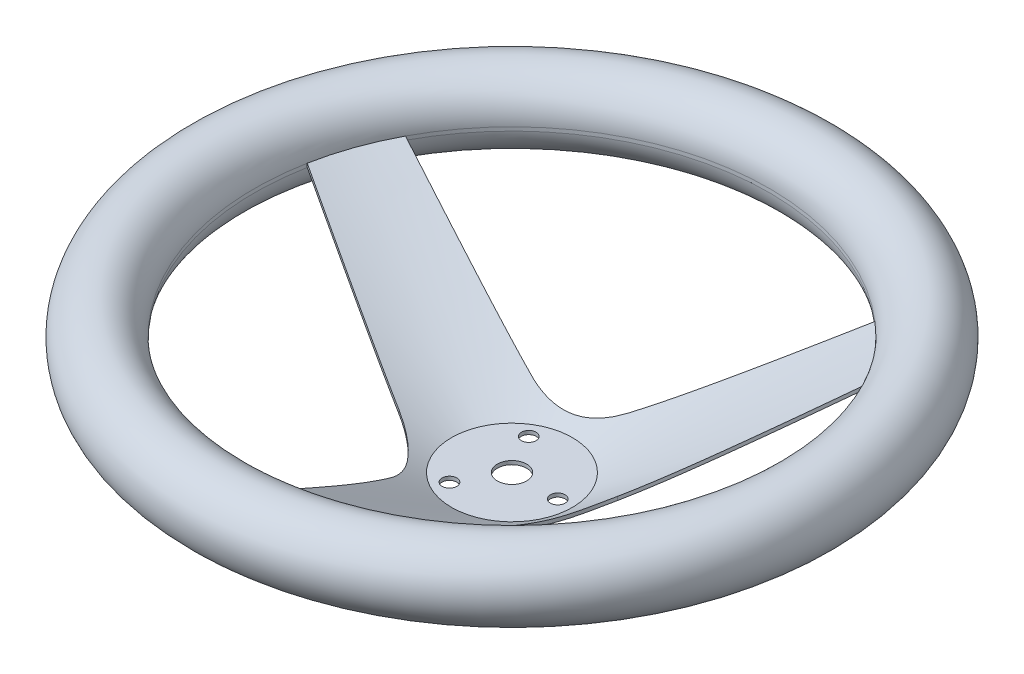
from build123d import *

# Parameters (mm, degrees)
SKETCH7_R           = 26.162
BOSS_EXTRUDE4_DEPTH = 52.3875
SKETCH8_R           = 26.162
CUT_EXTRUDE1_DEPTH  = 50.8
SKETCH9_R           = 15.621
CUT_EXTRUDE2_DEPTH  = 50.8
SKETCH11_R          = 6.35
SKETCH11_R_2        = 3.175
CUT_EXTRUDE3_DEPTH  = 2.54


with BuildPart() as part:
    # Sketch7 → Boss-Extrude4 (new body)
    with BuildSketch(Plane(origin=(0, 0, 0), x_dir=(1, 0, 0), z_dir=(0, 1, 0))):
        Circle(SKETCH7_R)
    extrude(amount=-BOSS_EXTRUDE4_DEPTH)

    # Sketch8 → Cut-Extrude1 (cut)
    with BuildSketch(Plane(origin=(0, 0, 0), x_dir=(1, 0, 0), z_dir=(0, 1, 0))):
        Circle(SKETCH8_R)
    extrude(amount=-CUT_EXTRUDE1_DEPTH, mode=Mode.SUBTRACT)

    # Sketch9 → Revolve4 (revolve)
    with BuildSketch(Plane.XY):
        with Locations((127, 0)):
            Circle(SKETCH9_R)
        with BuildLine():
            Line((111.379, 0), (26.162, -50.8))
            Line((26.162, -50.8), (26.162, -52.3875))
            Line((26.162, -52.3875), (111.455296032, -1.542018014))
            ThreePointArc((111.455296032, -1.542018014), (111.398085667, -0.771952174), (111.379, 0))
        make_face()
    revolve(axis=Axis((0, 0, 0), (0, -1, 0)))

    # Sketch10 → Cut-Extrude2 (cut)
    with BuildSketch(Plane(origin=(0, 0, 0), x_dir=(1, 0, 0), z_dir=(0, 1, 0))):
        with BuildLine():
            Line((94.435825911, 59.05215005), (40.549922786, 5.174980076))
            ThreePointArc((40.549922786, 5.174980076), (30.157026479, -10.65685708), (27.946773619, -29.465741782))
            Line((27.946773619, -29.465741782), (36.689563988, -105.162529141))
            ThreePointArc((36.689563988, -105.162529141), (105.071795381, -36.94860561), (94.435825911, 59.05215005))
        make_face()
        with BuildLine():
            Line((11.544694115, 38.935486799), (72.728639768, 84.355359038))
            ThreePointArc((72.728639768, 84.355359038), (-20.537466598, 109.469146826), (-98.358575047, 52.257749241))
            Line((-98.358575047, 52.257749241), (-24.756625603, 32.529773216))
            ThreePointArc((-24.756625603, 32.529773216), (-5.849404283, 31.445179573), (11.544694115, 38.935486799))
        make_face()
        with BuildLine():
            Line((3.922749136, -111.309899291), (-15.793297183, -37.704753292))
            ThreePointArc((-15.793297183, -37.704753292), (-24.307622195, -20.788322493), (-39.491467734, -9.469745017))
            Line((-39.491467734, -9.469745017), (-109.418203757, 20.807170103))
            ThreePointArc((-109.418203757, 20.807170103), (-84.534328783, -72.520541216), (3.922749136, -111.309899291))
        make_face()
    extrude(amount=-CUT_EXTRUDE2_DEPTH, mode=Mode.SUBTRACT)

    # Sketch11 → Cut-Extrude3 (cut)
    with BuildSketch(Plane(origin=(0, -50.8, 0), x_dir=(1, 0, 0), z_dir=(0, 1, 0))):
        Circle(SKETCH11_R)
        with Locations((19.812, 0)):
            Circle(SKETCH11_R_2)
        with Locations((-9.906, 17.1576953)):
            Circle(SKETCH11_R_2)
        with Locations((-9.906, -17.1576953)):
            Circle(SKETCH11_R_2)
    extrude(amount=-CUT_EXTRUDE3_DEPTH, mode=Mode.SUBTRACT)


solid = part.part
